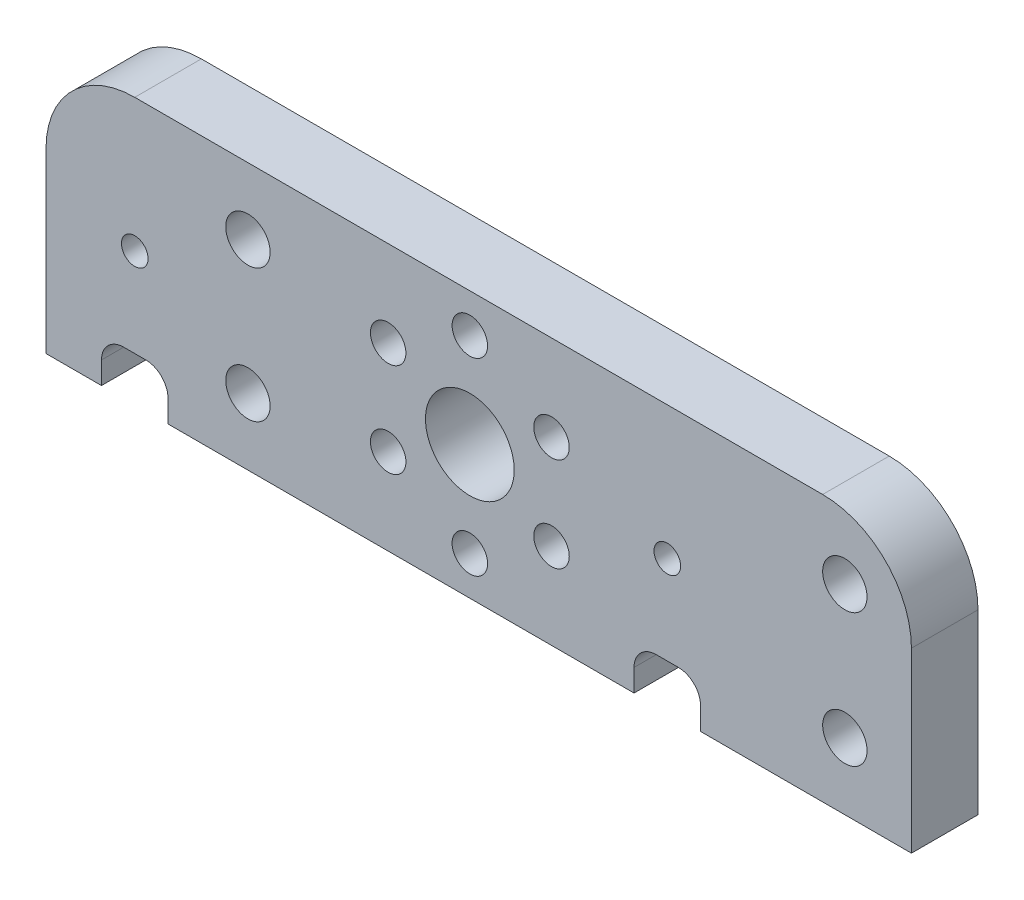
from build123d import *

# Parameters (mm, degrees)
SKETCH1_R           = 1
SKETCH1_R_2         = 0.6
SKETCH1_R_3         = 2
BOSS_EXTRUDE1_DEPTH = 3
SKETCH3_R           = 0.8
CUT_EXTRUDE1_DEPTH  = 3
CIRPATTERN1_COUNT   = 6


with BuildPart() as part:
    # Sketch1 → Boss-Extrude1 (new body)
    with BuildSketch(Plane.XY):
        with BuildLine():
            Line((-23.1, 2), (-23.1, -6))
            Line((-23.1, -6), (-20.6, -6))
            Line((-20.6, -6), (-20.6, -5))
            ThreePointArc((-20.6, -5), (-20.307106781, -4.292893219), (-19.6, -4))
            Line((-19.6, -4), (-18.6, -4))
            ThreePointArc((-18.6, -4), (-17.892893219, -4.292893219), (-17.6, -5))
            Line((-17.6, -5), (-17.6, -6))
            Line((-17.6, -6), (3.4, -6))
            Line((3.4, -6), (3.4, -5))
            ThreePointArc((3.4, -5), (3.692893219, -4.292893219), (4.4, -4))
            Line((4.4, -4), (5.4, -4))
            ThreePointArc((5.4, -4), (6.107106781, -4.292893219), (6.4, -5))
            Line((6.4, -5), (6.4, -6))
            Line((6.4, -6), (15.9, -6))
            Line((15.9, -6), (15.9, 2))
            ThreePointArc((15.9, 2), (14.728427125, 4.828427125), (11.9, 6))
            Line((11.9, 6), (-19.1, 6))
            ThreePointArc((-19.1, 6), (-21.928427125, 4.828427125), (-23.1, 2))
        make_face()
        with Locations((-14, -3)):
            Circle(SKETCH1_R, mode=Mode.SUBTRACT)
        with Locations((12.9, -3)):
            Circle(SKETCH1_R, mode=Mode.SUBTRACT)
        with Locations((-19.1, 0)):
            Circle(SKETCH1_R_2, mode=Mode.SUBTRACT)
        with Locations((-14, 3)):
            Circle(SKETCH1_R, mode=Mode.SUBTRACT)
        with Locations((-4, 0)):
            Circle(SKETCH1_R_3, mode=Mode.SUBTRACT)
        with Locations((4.9, 0)):
            Circle(SKETCH1_R_2, mode=Mode.SUBTRACT)
        with Locations((12.9, 3)):
            Circle(SKETCH1_R, mode=Mode.SUBTRACT)
    extrude(amount=BOSS_EXTRUDE1_DEPTH)

    # Sketch3 → Cut-Extrude1 (cut)
    with BuildSketch(Plane.XY.offset(3)):
        with Locations((-4, 4.25)):
            Circle(SKETCH3_R)
    cut_extrude1 = extrude(amount=-CUT_EXTRUDE1_DEPTH, mode=Mode.SUBTRACT)

    # CirPattern1: Cut-Extrude1 ×6 about axis
    cirpattern1_axis = Axis((-4, 0, 0), (0, 0, 1))
    for i in range(1, CIRPATTERN1_COUNT):
        add(cut_extrude1.rotate(cirpattern1_axis, i * 360 / CIRPATTERN1_COUNT), mode=Mode.SUBTRACT)


solid = part.part
